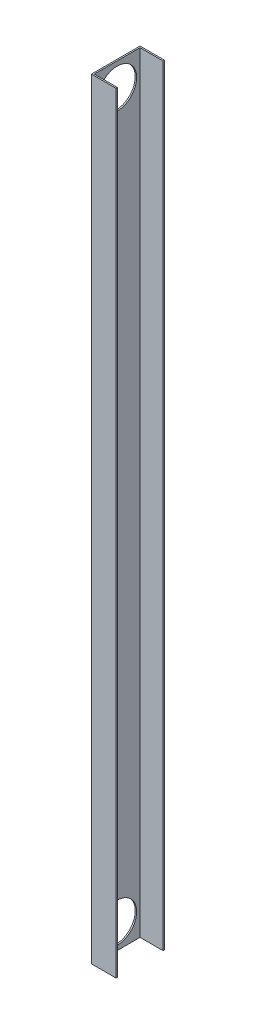
from build123d import *

# Parameters (mm, degrees)
BOSS_EXTRUDE2_DEPTH = 1600
SKETCH3_R           = 40.5
CUT_EXTRUDE2_DEPTH  = 52


with BuildPart() as part:
    # Sketch2 → Boss-Extrude2 (new body)
    with BuildSketch(Plane(origin=(0, 0, 0), x_dir=(1, 0, 0), z_dir=(0, 1, 0))):
        Polygon((-22.5, 47.5), (25.5, 47.5), (25.5, 50.5), (-25.5, 50.5), (-25.5, -50.5), (25.5, -50.5), (25.5, -47.5), (-22.5, -47.5), align=None)
    extrude(amount=BOSS_EXTRUDE2_DEPTH)

    # Sketch3 → Cut-Extrude2 (cut, through all)
    with BuildSketch(Plane.ZY.offset(25.5)):
        with Locations((0, 50)):
            Circle(SKETCH3_R)
        with Locations((0, 1550)):
            Circle(SKETCH3_R)
    extrude(amount=-CUT_EXTRUDE2_DEPTH, mode=Mode.SUBTRACT)


solid = part.part
